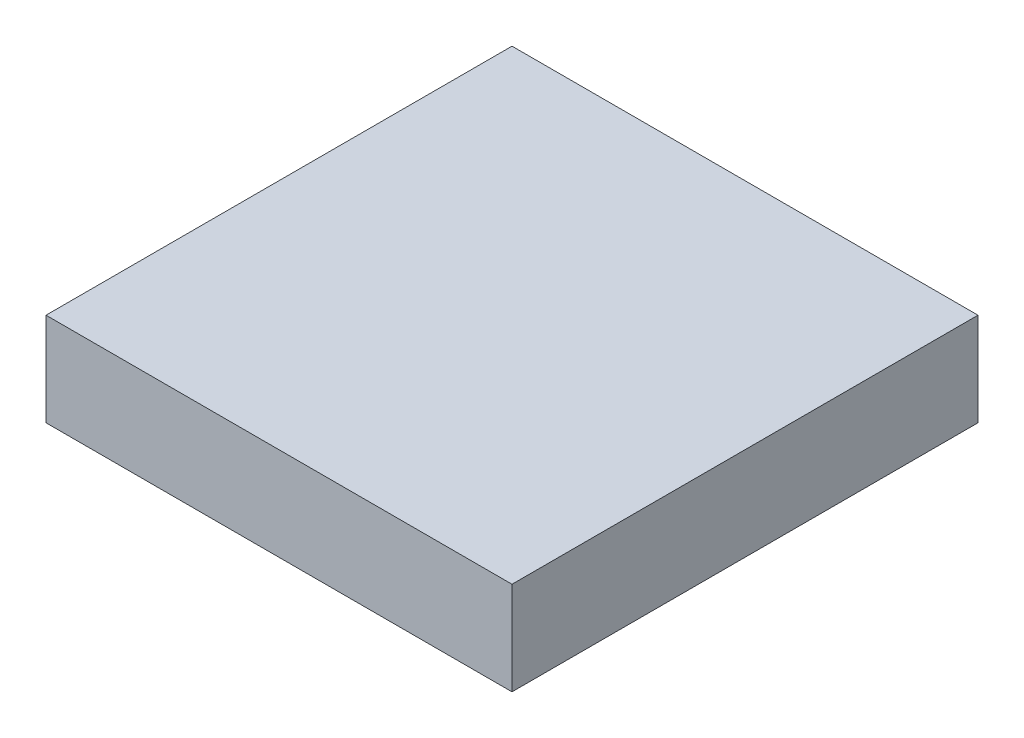
from build123d import *

# Parameters (mm, degrees)
SKETCH_1_W      = 3.5
SKETCH_1_H      = 3.5
EXTRUDE_1_DEPTH = 0.7


with BuildPart() as part:
    # Эскиз1 → Бобышка-Вытянуть1 (new body)
    with BuildSketch(Plane(origin=(0, 0, 0), x_dir=(1, 0, 0), z_dir=(0, 1, 0))):
        Rectangle(SKETCH_1_W, SKETCH_1_H)
    extrude(amount=EXTRUDE_1_DEPTH)


solid = part.part
